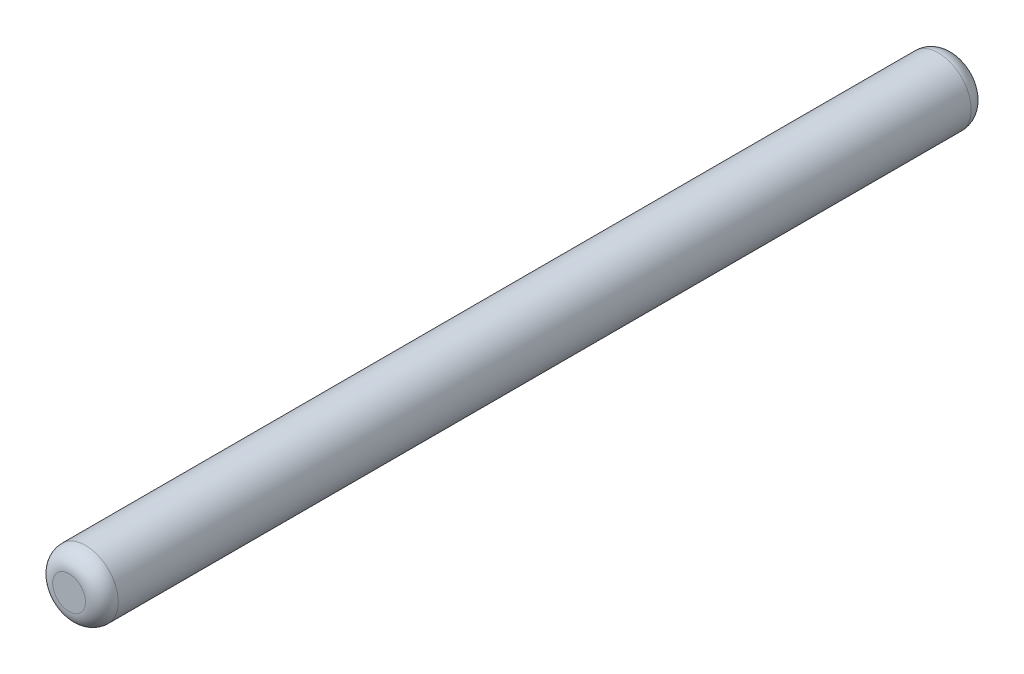
from build123d import *

# Parameters (mm, degrees)
SKETCH1_R           = 2
BOSS_EXTRUDE1_DEPTH = 27
FILLET1_R           = 1
FILLET2_R           = 1


with BuildPart() as part:
    # Sketch1 → Boss-Extrude1 (new body, symmetric)
    with BuildSketch(Plane.XY):
        Circle(SKETCH1_R)
    extrude(amount=BOSS_EXTRUDE1_DEPTH, both=True)

    # Fillet1
    fillet1_edges = [part.edges().sort_by_distance(p)[0] for p in [
        (-2, 0, 27),
    ]]
    fillet(fillet1_edges, radius=FILLET1_R)

    # Fillet2
    fillet2_edges = [part.edges().sort_by_distance(p)[0] for p in [
        (-2, 0, -27),
    ]]
    fillet(fillet2_edges, radius=FILLET2_R)


solid = part.part
